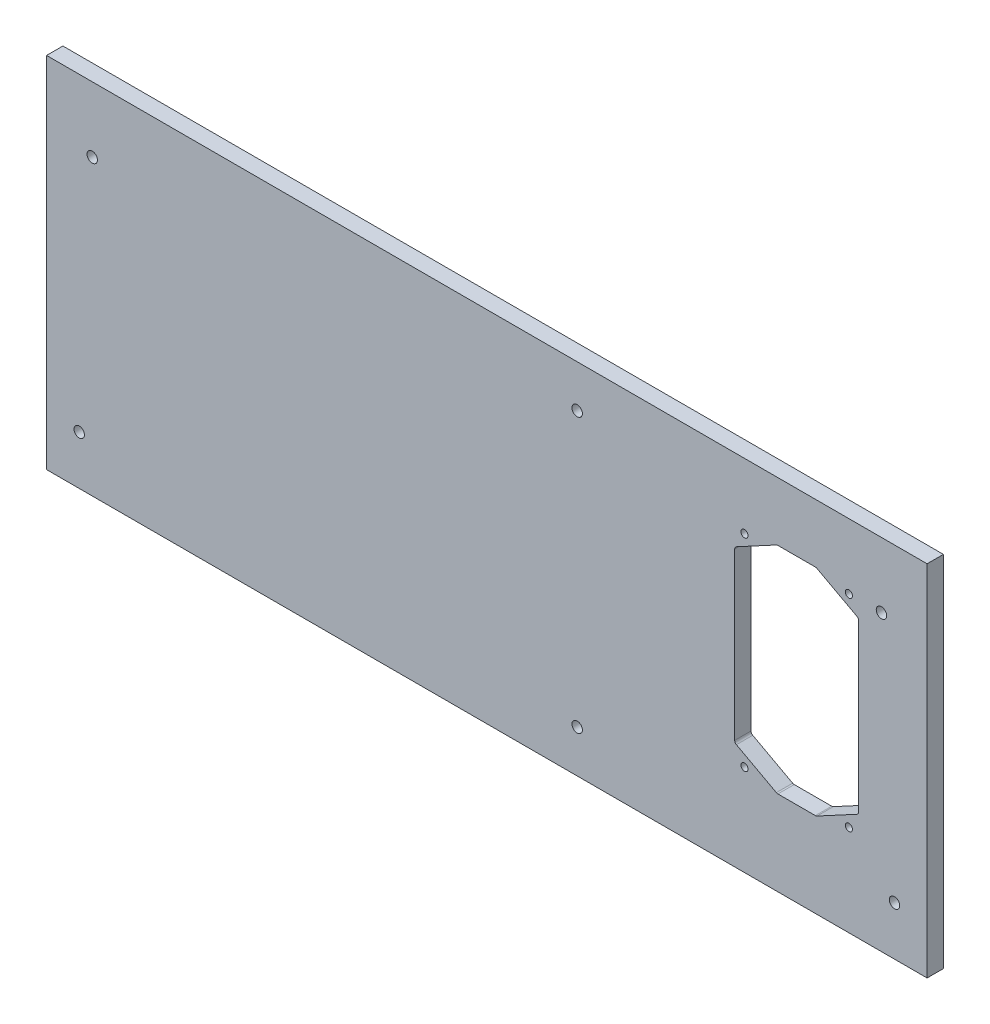
from build123d import *

# Parameters (mm, degrees)
SKETCH1_W                             = 270
SKETCH1_H                             = 110
SHEET_DEPTH                           = 2.5
SKETCH4_R                             = 1.1
CUT_EXTRUDE1_DEPTH                    = 6
FILLET1_R                             = 1
F_3_2_3_2_MOUNTHOLES_D                = 3.2
F_3_2_3_2_MOUNTHOLES_CSINK_D          = 6.5
F_3_2_3_2_MOUNTHOLES_CSINK_ANGLE      = 90
F_3_2_3_2_MIDDLEPARTHOLES_D           = 3.2
F_3_2_3_2_MIDDLEPARTHOLES_CSINK_D     = 6.5
F_3_2_3_2_MIDDLEPARTHOLES_CSINK_ANGLE = 90


with BuildPart() as part:
    # Sketch1 → Sheet (new body, symmetric)
    with BuildSketch(Plane.XY):
        Rectangle(SKETCH1_W, SKETCH1_H)
    extrude(amount=SHEET_DEPTH, both=True)

    # Sketch4 → Cut-Extrude1 (cut, through all)
    with BuildSketch(Plane(origin=(0, 0, -2.5), x_dir=(-1, 0, 0), z_dir=(0, 0, -1))):
        with Locations((-79, 35)):
            Circle(SKETCH4_R)
        with Locations((-111, 35)):
            Circle(SKETCH4_R)
        with Locations((-111, -27)):
            Circle(SKETCH4_R)
        with Locations((-79, -27)):
            Circle(SKETCH4_R)
        Polygon((-101, 37), (-114, 30), (-114, -22), (-101, -29), (-89, -29), (-76, -22), (-76, 30), (-89, 37), align=None)
    extrude(amount=-CUT_EXTRUDE1_DEPTH, mode=Mode.SUBTRACT)

    # Fillet1
    fillet1_edges = [part.edges().sort_by_distance(p)[0] for p in [
        (89, 37, 0),
        (76, 30, 0),
        (76, -22, 0),
        (89, -29, 0),
        (101, -29, 0),
        (114, -22, 0),
        (114, 30, 0),
        (101, 37, 0),
    ]]
    fillet(fillet1_edges, radius=FILLET1_R)

    # Ø3.2 (3.2) MountHoles (through all)
    with Locations(Plane(origin=(0, 0, -2.5), x_dir=(-1, 0, 0), z_dir=(0, 0, -1))):
        with Locations((-121, 35), (-125, -40), (125, -40), (121, 35)):
            CounterSinkHole(F_3_2_3_2_MOUNTHOLES_D / 2, F_3_2_3_2_MOUNTHOLES_CSINK_D / 2, counter_sink_angle=F_3_2_3_2_MOUNTHOLES_CSINK_ANGLE)

    # Ø3.2 (3.2) MiddlePartHoles (through all)
    with Locations(Plane(origin=(0, 0, -2.5), x_dir=(-1, 0, 0), z_dir=(0, 0, -1))):
        with Locations((-27.7, 42), (-27.7, -42)):
            CounterSinkHole(F_3_2_3_2_MIDDLEPARTHOLES_D / 2, F_3_2_3_2_MIDDLEPARTHOLES_CSINK_D / 2, counter_sink_angle=F_3_2_3_2_MIDDLEPARTHOLES_CSINK_ANGLE)


solid = part.part
